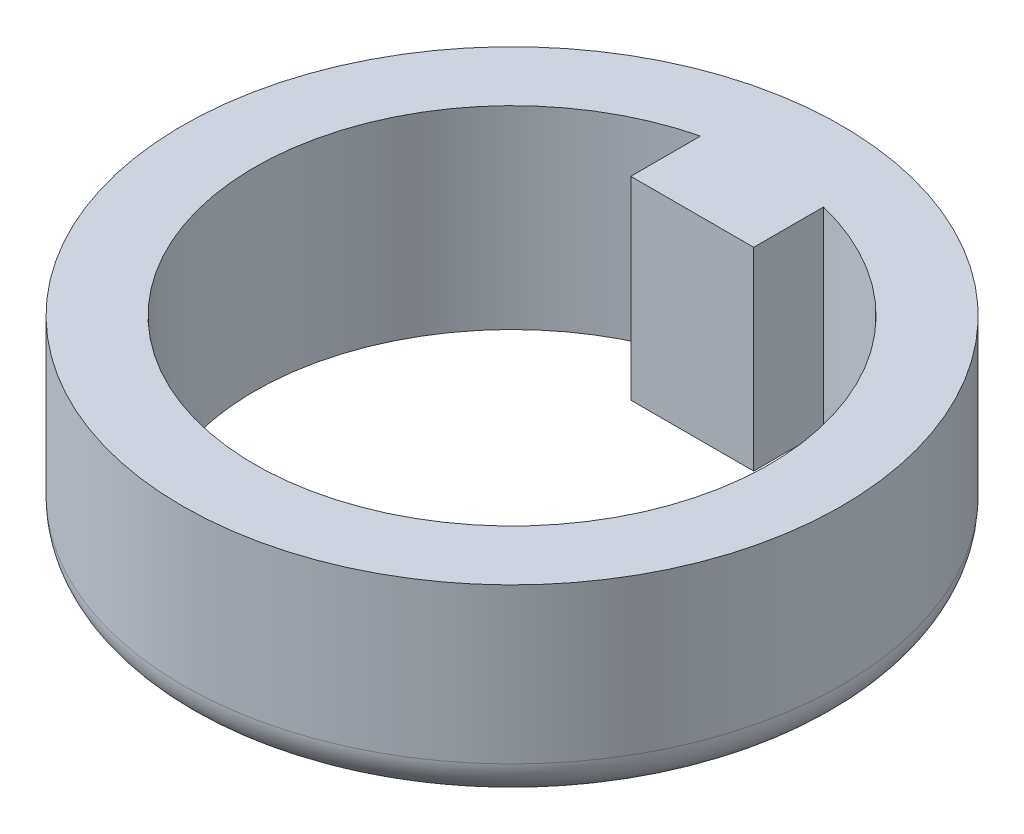
from build123d import *

# Parameters (mm, degrees)
SKETCH1_R           = 8.5
BOSS_EXTRUDE1_DEPTH = 5
FILLET3_R           = 1


with BuildPart() as part:
    # Sketch1 → Boss-Extrude1 (new body)
    with BuildSketch(Plane(origin=(0, 0, 0), x_dir=(1, 0, 0), z_dir=(0, 1, 0))):
        Circle(SKETCH1_R)
        with BuildLine():
            Line((-1.585, 6.447022258), (-1.585, 4.647022258))
            Line((-1.585, 4.647022258), (1.585, 4.647022258))
            Line((1.585, 4.647022258), (1.585, 6.447022258))
            ThreePointArc((1.585, 6.447022258), (0, -6.639), (-1.585, 6.447022258))
        make_face(mode=Mode.SUBTRACT)
    extrude(amount=BOSS_EXTRUDE1_DEPTH)

    # Fillet3
    fillet3_edges = [part.edges().sort_by_distance(p)[0] for p in [
        (-8.5, 0, 0),
    ]]
    fillet(fillet3_edges, radius=FILLET3_R)


solid = part.part
